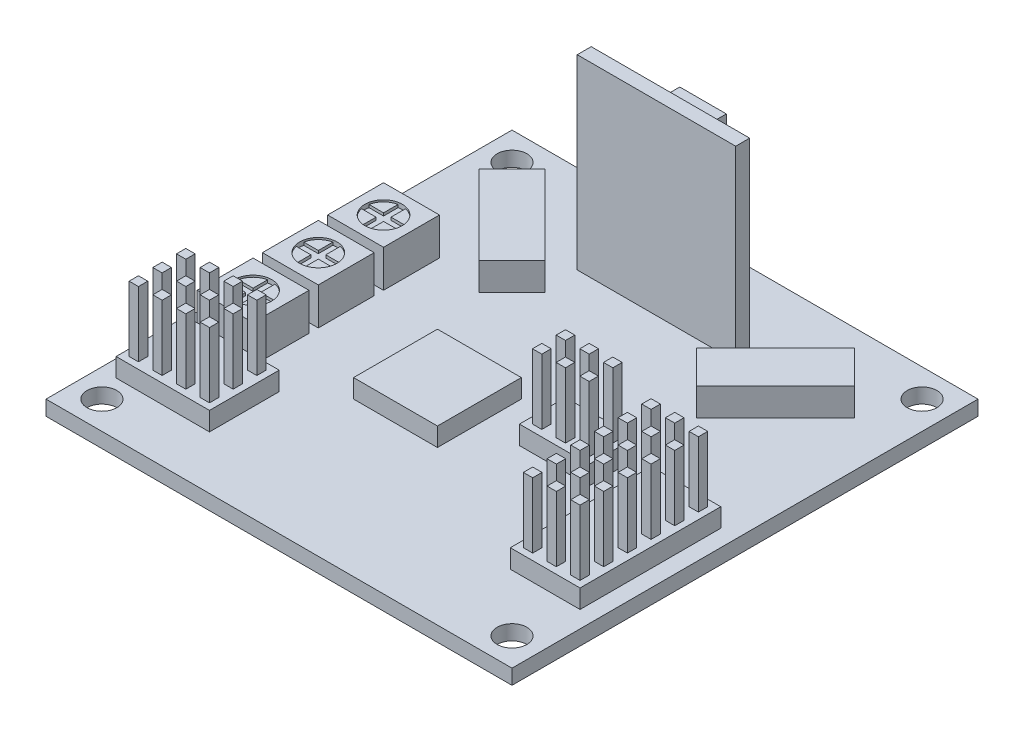
from build123d import *

# Parameters (mm, degrees)
SKETCH1_W            = 50
SKETCH1_H            = 50
SKETCH1_R            = 1.6
BOSS_EXTRUDE1_DEPTH  = 1.6
SKETCH2_W            = 6
SKETCH2_H            = 6
BOSS_EXTRUDE2_DEPTH  = 4
SKETCH3_R            = 2
CUT_EXTRUDE1_DEPTH   = 0.2
CUT_EXTRUDE2_DEPTH   = 0.5
SKETCH5_W            = 17
SKETCH5_H            = 1.5
BOSS_EXTRUDE3_DEPTH  = 20
SKETCH6_W            = 10.16
SKETCH6_H            = 3
BOSS_EXTRUDE4_DEPTH  = 2
BOSS_EXTRUDE5_DEPTH  = 3
SKETCH8_W            = 5
SKETCH8_H            = 12
BOSS_EXTRUDE6_DEPTH  = 3
SKETCH9_W            = 9
SKETCH9_H            = 9
BOSS_EXTRUDE7_DEPTH  = 2
SKETCH10_W           = 1
SKETCH10_H           = 1
BOSS_EXTRUDE8_DEPTH  = 9
SKETCH11_W           = 10.02
SKETCH11_H           = 7.48
SKETCH11_W_2         = 7.48
SKETCH11_H_2         = 4.94
SKETCH11_H_3         = 15.1
BOSS_EXTRUDE10_DEPTH = 2


with BuildPart() as part:
    # Sketch1 → Boss-Extrude1 (new body)
    with BuildSketch(Plane(origin=(0, 0, 0), x_dir=(1, 0, 0), z_dir=(0, 1, 0))):
        Rectangle(SKETCH1_W, SKETCH1_H)
        with Locations((-22, 22)):
            Circle(SKETCH1_R, mode=Mode.SUBTRACT)
        with Locations((22, 22)):
            Circle(SKETCH1_R, mode=Mode.SUBTRACT)
        with Locations((22, -22)):
            Circle(SKETCH1_R, mode=Mode.SUBTRACT)
        with Locations((-22, -22)):
            Circle(SKETCH1_R, mode=Mode.SUBTRACT)
    extrude(amount=BOSS_EXTRUDE1_DEPTH)

    # Sketch2 → Boss-Extrude2 (add)
    with BuildSketch(Plane(origin=(0, 1.6, 0), x_dir=(1, 0, 0), z_dir=(0, 1, 0))):
        with Locations((-20, -0.783142)):
            Rectangle(SKETCH2_W, SKETCH2_H)
        with Locations((-20, 6.216858)):
            Rectangle(SKETCH2_W, SKETCH2_H)
        with Locations((-20, -7.783142)):
            Rectangle(SKETCH2_W, SKETCH2_H)
    extrude(amount=BOSS_EXTRUDE2_DEPTH)

    # Sketch3 → Cut-Extrude1 (cut)
    with BuildSketch(Plane(origin=(0, 5.6, 0), x_dir=(1, 0, 0), z_dir=(0, 1, 0))):
        with Locations((-20, 6.216858)):
            Circle(SKETCH3_R)
        with Locations((-20, -0.783142)):
            Circle(SKETCH3_R)
        with Locations((-20, -7.783142)):
            Circle(SKETCH3_R)
    extrude(amount=-CUT_EXTRUDE1_DEPTH, mode=Mode.SUBTRACT)

    # Sketch4 → Cut-Extrude2 (cut)
    with BuildSketch(Plane(origin=(0, 5.6, 0), x_dir=(1, 0, 0), z_dir=(0, 1, 0))):
        with BuildLine():
            Line((-20.4, 6.616858), (-21.959592, 6.616858))
            ThreePointArc((-21.959592, 6.616858), (-22, 6.216858), (-21.959592, 5.816858))
            Line((-21.959592, 5.816858), (-20.4, 5.816858))
            Line((-20.4, 5.816858), (-20.4, 4.257266))
            ThreePointArc((-20.4, 4.257266), (-20, 4.216858), (-19.6, 4.257266))
            Line((-19.6, 4.257266), (-19.6, 5.816858))
            Line((-19.6, 5.816858), (-18.040408, 5.816858))
            ThreePointArc((-18.040408, 5.816858), (-18.010128, 6.01584), (-18, 6.216858))
            ThreePointArc((-18, 6.216858), (-18.010128, 6.417876), (-18.040408, 6.616858))
            Line((-18.040408, 6.616858), (-19.6, 6.616858))
            Line((-19.6, 6.616858), (-19.6, 8.17645))
            ThreePointArc((-19.6, 8.17645), (-20, 8.216858), (-20.4, 8.17645))
            Line((-20.4, 8.17645), (-20.4, 6.616858))
        make_face()
        with BuildLine():
            Line((-20.4, -2.742734), (-20.4, -1.183142))
            Line((-20.4, -1.183142), (-21.959592, -1.183142))
            ThreePointArc((-21.959592, -1.183142), (-22, -0.783142), (-21.959592, -0.383142))
            Line((-21.959592, -0.383142), (-20.4, -0.383142))
            Line((-20.4, -0.383142), (-20.4, 1.17645))
            ThreePointArc((-20.4, 1.17645), (-20, 1.216858), (-19.6, 1.17645))
            Line((-19.6, 1.17645), (-19.6, -0.383142))
            Line((-19.6, -0.383142), (-18.040408, -0.383142))
            ThreePointArc((-18.040408, -0.383142), (-18, -0.783142), (-18.040408, -1.183142))
            Line((-18.040408, -1.183142), (-19.6, -1.183142))
            Line((-19.6, -1.183142), (-19.6, -2.742734))
            ThreePointArc((-19.6, -2.742734), (-20, -2.783142), (-20.4, -2.742734))
        make_face()
        with BuildLine():
            Line((-20.4, -9.742734), (-20.4, -8.183142))
            Line((-20.4, -8.183142), (-21.959592, -8.183142))
            ThreePointArc((-21.959592, -8.183142), (-22, -7.783142), (-21.959592, -7.383142))
            Line((-21.959592, -7.383142), (-20.4, -7.383142))
            Line((-20.4, -7.383142), (-20.4, -5.82355))
            ThreePointArc((-20.4, -5.82355), (-20, -5.783142), (-19.6, -5.82355))
            Line((-19.6, -5.82355), (-19.6, -7.383142))
            Line((-19.6, -7.383142), (-18.040408, -7.383142))
            ThreePointArc((-18.040408, -7.383142), (-18, -7.783142), (-18.040408, -8.183142))
            Line((-18.040408, -8.183142), (-19.6, -8.183142))
            Line((-19.6, -8.183142), (-19.6, -9.742734))
            ThreePointArc((-19.6, -9.742734), (-20, -9.783142), (-20.4, -9.742734))
        make_face()
    extrude(amount=-CUT_EXTRUDE2_DEPTH, mode=Mode.SUBTRACT)

    # Sketch5 → Boss-Extrude3 (add)
    with BuildSketch(Plane(origin=(0, 1.6, 0), x_dir=(1, 0, 0), z_dir=(0, 1, 0))):
        with Locations((0, 16.25)):
            Rectangle(SKETCH5_W, SKETCH5_H)
    extrude(amount=BOSS_EXTRUDE3_DEPTH)

    # Sketch6 → Boss-Extrude4 (add)
    with BuildSketch(Plane(origin=(0, 1.6, 0), x_dir=(1, 0, 0), z_dir=(0, 1, 0))):
        with Locations((0, 17)):
            Rectangle(SKETCH6_W, SKETCH6_H)
    extrude(amount=BOSS_EXTRUDE4_DEPTH)

    # Sketch7 → Boss-Extrude5 (add)
    with BuildSketch(Plane(origin=(0, 1.6, 0), x_dir=(1, 0, 0), z_dir=(0, 1, 0))):
        Polygon((-20.152543, 16.617009), (-11.667262, 8.131728), (-8.131728, 11.667262), (-16.617009, 20.152543), align=None)
        Polygon((16.617009, 20.152543), (8.131728, 11.667262), (11.667262, 8.131728), (20.152543, 16.617009), align=None)
    extrude(amount=BOSS_EXTRUDE5_DEPTH)

    # Sketch8 → Boss-Extrude6 (add)
    with BuildSketch(Plane(origin=(0, 0, -17), x_dir=(-1, 0, 0), z_dir=(0, 0, -1))):
        with Locations((-0.5, 13.6)):
            Rectangle(SKETCH8_W, SKETCH8_H)
    extrude(amount=BOSS_EXTRUDE6_DEPTH)

    # Sketch9 → Boss-Extrude7 (add)
    with BuildSketch(Plane(origin=(0, 1.6, 0), x_dir=(1, 0, 0), z_dir=(0, 1, 0))):
        with Locations((-4, -4)):
            Rectangle(SKETCH9_W, SKETCH9_H)
    extrude(amount=BOSS_EXTRUDE7_DEPTH)

    # Sketch10 → Boss-Extrude8 (add)
    with BuildSketch(Plane(origin=(0, 1.6, 0), x_dir=(1, 0, 0), z_dir=(0, 1, 0))):
        with Locations((-19.46, -13)):
            Rectangle(SKETCH10_W, SKETCH10_H)
        with Locations((-22, -13)):
            Rectangle(SKETCH10_W, SKETCH10_H)
        with Locations((-16.92, -13)):
            Rectangle(SKETCH10_W, SKETCH10_H)
        with Locations((-14.38, -13)):
            Rectangle(SKETCH10_W, SKETCH10_H)
        with Locations((-19.46, -15.54)):
            Rectangle(SKETCH10_W, SKETCH10_H)
        with Locations((-16.92, -15.54)):
            Rectangle(SKETCH10_W, SKETCH10_H)
        with Locations((-14.38, -15.54)):
            Rectangle(SKETCH10_W, SKETCH10_H)
        with Locations((-19.46, -18.08)):
            Rectangle(SKETCH10_W, SKETCH10_H)
        with Locations((-16.92, -18.08)):
            Rectangle(SKETCH10_W, SKETCH10_H)
        with Locations((-14.38, -18.08)):
            Rectangle(SKETCH10_W, SKETCH10_H)
        with Locations((-22, -15.54)):
            Rectangle(SKETCH10_W, SKETCH10_H)
        with Locations((-22, -18.08)):
            Rectangle(SKETCH10_W, SKETCH10_H)
        with Locations((22, -2)):
            Rectangle(SKETCH10_W, SKETCH10_H)
        with Locations((19.46, -2)):
            Rectangle(SKETCH10_W, SKETCH10_H)
        with Locations((16.92, -2)):
            Rectangle(SKETCH10_W, SKETCH10_H)
        with Locations((19.46, -4.54)):
            Rectangle(SKETCH10_W, SKETCH10_H)
        with Locations((16.92, -4.54)):
            Rectangle(SKETCH10_W, SKETCH10_H)
        with Locations((19.46, -7.08)):
            Rectangle(SKETCH10_W, SKETCH10_H)
        with Locations((16.92, -7.08)):
            Rectangle(SKETCH10_W, SKETCH10_H)
        with Locations((19.46, -9.62)):
            Rectangle(SKETCH10_W, SKETCH10_H)
        with Locations((16.92, -9.62)):
            Rectangle(SKETCH10_W, SKETCH10_H)
        with Locations((19.46, -12.16)):
            Rectangle(SKETCH10_W, SKETCH10_H)
        with Locations((16.92, -12.16)):
            Rectangle(SKETCH10_W, SKETCH10_H)
        with Locations((19.46, -14.7)):
            Rectangle(SKETCH10_W, SKETCH10_H)
        with Locations((16.92, -14.7)):
            Rectangle(SKETCH10_W, SKETCH10_H)
        with Locations((22, -4.54)):
            Rectangle(SKETCH10_W, SKETCH10_H)
        with Locations((22, -7.08)):
            Rectangle(SKETCH10_W, SKETCH10_H)
        with Locations((22, -9.62)):
            Rectangle(SKETCH10_W, SKETCH10_H)
        with Locations((22, -12.16)):
            Rectangle(SKETCH10_W, SKETCH10_H)
        with Locations((22, -14.7)):
            Rectangle(SKETCH10_W, SKETCH10_H)
        with Locations((8.46, -0.182312)):
            Rectangle(SKETCH10_W, SKETCH10_H)
        with Locations((11, -0.182312)):
            Rectangle(SKETCH10_W, SKETCH10_H)
        with Locations((5.92, -0.182312)):
            Rectangle(SKETCH10_W, SKETCH10_H)
        with Locations((8.46, -2.722312)):
            Rectangle(SKETCH10_W, SKETCH10_H)
        with Locations((5.92, -2.722312)):
            Rectangle(SKETCH10_W, SKETCH10_H)
        with Locations((11, -2.722312)):
            Rectangle(SKETCH10_W, SKETCH10_H)
    extrude(amount=BOSS_EXTRUDE8_DEPTH)

    # Sketch11 → Boss-Extrude10 (add)
    with BuildSketch(Plane(origin=(0, 1.6, 0), x_dir=(1, 0, 0), z_dir=(0, 1, 0))):
        with Locations((-18.19, -15.54)):
            Rectangle(SKETCH11_W, SKETCH11_H)
        with Locations((8.46, -1.452312)):
            Rectangle(SKETCH11_W_2, SKETCH11_H_2)
        with Locations((19.46, -8.35)):
            Rectangle(SKETCH11_W_2, SKETCH11_H_3)
    extrude(amount=BOSS_EXTRUDE10_DEPTH)


solid = part.part
